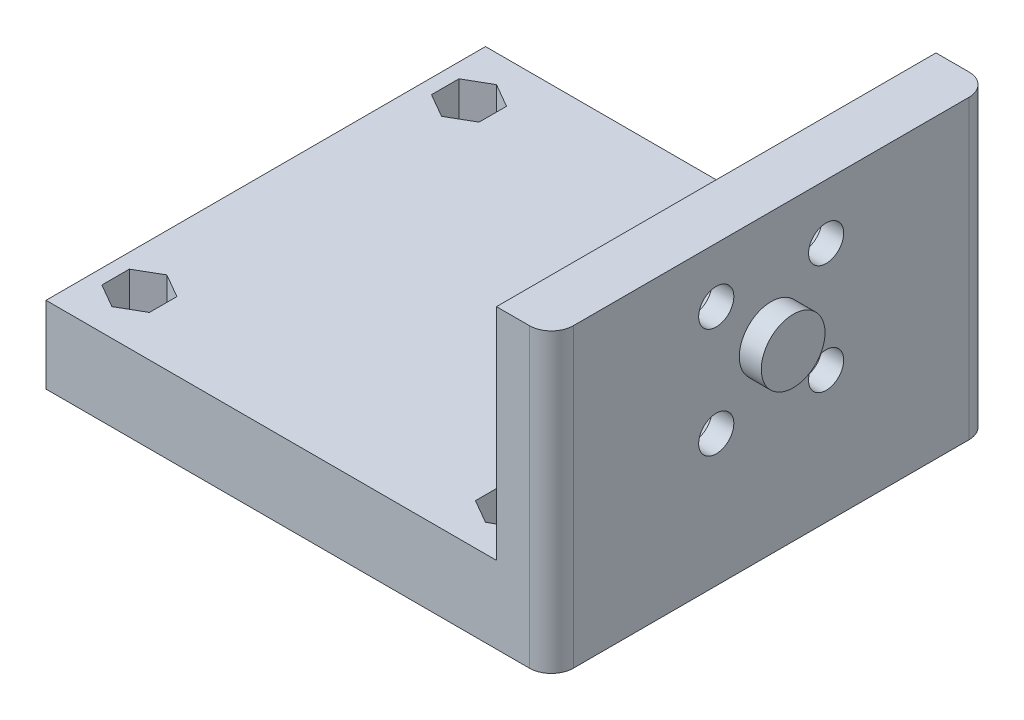
from build123d import *

# Parameters (mm, degrees)
ESQUISSE1_W             = 5
ESQUISSE1_H             = 40
BOSS_EXTRU_1_DEPTH      = 27
ESQUISSE2_W             = 40
ESQUISSE2_H             = 7
BOSS_EXTRU_2_DEPTH      = 41
CONG_1_R                = 2
ENL_V_MAT_EXTRU_1_REACH = 48
ESQUISSE4_R             = 1.6
ESQUISSE5_R             = 2.9
BOSS_EXTRU_3_DEPTH      = 2
ENL_V_MAT_EXTRU_3_DEPTH = 3
ESQUISSE9_R             = 1.1
ENL_V_MAT_EXTRU_5_DEPTH = 8
ENL_V_MAT_EXTRU_4_DEPTH = 4


with BuildPart() as part:
    # Esquisse1 → Boss.-Extru.1 (new body)
    with BuildSketch(Plane(origin=(0, 0, 0), x_dir=(1, 0, 0), z_dir=(0, 1, 0))):
        with Locations((-2.5, 0)):
            Rectangle(ESQUISSE1_W, ESQUISSE1_H)
    extrude(amount=-BOSS_EXTRU_1_DEPTH)

    # Esquisse2 → Boss.-Extru.2 (add)
    with BuildSketch(Plane.ZY.offset(5)):
        with Locations((0, -23.5)):
            Rectangle(ESQUISSE2_W, ESQUISSE2_H)
    extrude(amount=BOSS_EXTRU_2_DEPTH)

    # Congé1
    cong_1_edges = [part.edges().sort_by_distance(p)[0] for p in [
        (0, -13.5, 20),
        (0, -13.5, -20),
    ]]
    fillet(cong_1_edges, radius=CONG_1_R)

    # Esquisse4 → Enlèv. mat.-Extru.1 (cut, up to next)
    with BuildSketch(Plane(origin=(0, 0, 0), x_dir=(0, 0, -1), z_dir=(1, 0, 0)), mode=Mode.PRIVATE) as enl_v_mat_extru_1_sk1:
        with Locations((-5, -5)):
            Circle(ESQUISSE4_R)
    enl_v_mat_extru_1_tool1 = extrude(enl_v_mat_extru_1_sk1.sketch, amount=-ENL_V_MAT_EXTRU_1_REACH, mode=Mode.PRIVATE) & part.part
    add(enl_v_mat_extru_1_tool1.solids().sort_by_distance((0, -5, 5))[0], mode=Mode.SUBTRACT)
    # Esquisse4 → Enlèv. mat.-Extru.1 (cut, up to next)
    with BuildSketch(Plane(origin=(0, 0, 0), x_dir=(0, 0, -1), z_dir=(1, 0, 0)), mode=Mode.PRIVATE) as enl_v_mat_extru_1_sk2:
        with Locations((5, -5)):
            Circle(ESQUISSE4_R)
    enl_v_mat_extru_1_tool2 = extrude(enl_v_mat_extru_1_sk2.sketch, amount=-ENL_V_MAT_EXTRU_1_REACH, mode=Mode.PRIVATE) & part.part
    add(enl_v_mat_extru_1_tool2.solids().sort_by_distance((0, -5, -5))[0], mode=Mode.SUBTRACT)
    # Esquisse4 → Enlèv. mat.-Extru.1 (cut, up to next)
    with BuildSketch(Plane(origin=(0, 0, 0), x_dir=(0, 0, -1), z_dir=(1, 0, 0)), mode=Mode.PRIVATE) as enl_v_mat_extru_1_sk3:
        with Locations((-5, -15)):
            Circle(ESQUISSE4_R)
    enl_v_mat_extru_1_tool3 = extrude(enl_v_mat_extru_1_sk3.sketch, amount=-ENL_V_MAT_EXTRU_1_REACH, mode=Mode.PRIVATE) & part.part
    add(enl_v_mat_extru_1_tool3.solids().sort_by_distance((0, -15, 5))[0], mode=Mode.SUBTRACT)
    # Esquisse4 → Enlèv. mat.-Extru.1 (cut, up to next)
    with BuildSketch(Plane(origin=(0, 0, 0), x_dir=(0, 0, -1), z_dir=(1, 0, 0)), mode=Mode.PRIVATE) as enl_v_mat_extru_1_sk4:
        with Locations((5, -15)):
            Circle(ESQUISSE4_R)
    enl_v_mat_extru_1_tool4 = extrude(enl_v_mat_extru_1_sk4.sketch, amount=-ENL_V_MAT_EXTRU_1_REACH, mode=Mode.PRIVATE) & part.part
    add(enl_v_mat_extru_1_tool4.solids().sort_by_distance((0, -15, -5))[0], mode=Mode.SUBTRACT)

    # Esquisse5 → Boss.-Extru.3 (add)
    with BuildSketch(Plane(origin=(0, 0, 0), x_dir=(0, 0, -1), z_dir=(1, 0, 0))):
        with Locations((0, -10)):
            Circle(ESQUISSE5_R)
    extrude(amount=BOSS_EXTRU_3_DEPTH)

    # Esquisse7 → Enlèv. mat.-Extru.3 (cut)
    with BuildSketch(Plane.ZY.offset(5)):
        Polygon((-3.25, -8.031088913), (-1.5, -5), (-3.25, -1.968911087), (-6.75, -1.968911087), (-8.5, -5), (-6.75, -8.031088913), align=None)
        Polygon((3.25, -1.968911087), (1.5, -5), (3.25, -8.031088913), (6.75, -8.031088913), (8.5, -5), (6.75, -1.968911087), align=None)
        Polygon((-3.25, -18.031088913), (-1.5, -15), (-3.25, -11.968911087), (-6.75, -11.968911087), (-8.5, -15), (-6.75, -18.031088913), align=None)
        Polygon((8.5, -15), (6.75, -11.968911087), (3.25, -11.968911087), (1.5, -15), (3.25, -18.031088913), (6.75, -18.031088913), align=None)
    extrude(amount=-ENL_V_MAT_EXTRU_3_DEPTH, mode=Mode.SUBTRACT)

    # Esquisse9 → Enlèv. mat.-Extru.5 (cut, through all)
    with BuildSketch(Plane(origin=(0, -20, 0), x_dir=(1, 0, 0), z_dir=(0, 1, 0))):
        with Locations(Location((-8.5, 15, 0), (0, 0, 270))):  # turned: the seam where the file's is
            Circle(ESQUISSE9_R)
        with Locations(Location((-8.5, -15, 0), (0, 0, 270))):  # turned: the seam where the file's is
            Circle(ESQUISSE9_R)
        with Locations(Location((-42.5, -15, 0), (0, 0, 270))):  # turned: the seam where the file's is
            Circle(ESQUISSE9_R)
        with Locations(Location((-42.5, 15, 0), (0, 0, 270))):  # turned: the seam where the file's is
            Circle(ESQUISSE9_R)
    extrude(amount=-ENL_V_MAT_EXTRU_5_DEPTH, mode=Mode.SUBTRACT)

    # Esquisse8 → Enlèv. mat.-Extru.4 (cut)
    with BuildSketch(Plane(origin=(0, -20, 0), x_dir=(1, 0, 0), z_dir=(0, 1, 0))):
        Polygon((-10.665063509, 13.75), (-8.5, 12.5), (-6.334936491, 13.75), (-6.334936491, 16.25), (-8.5, 17.5), (-10.665063509, 16.25), align=None)
        Polygon((-10.665063509, -16.25), (-8.5, -17.5), (-6.334936491, -16.25), (-6.334936491, -13.75), (-8.5, -12.5), (-10.665063509, -13.75), align=None)
        Polygon((-44.665063509, -16.25), (-42.5, -17.5), (-40.334936491, -16.25), (-40.334936491, -13.75), (-42.5, -12.5), (-44.665063509, -13.75), align=None)
        Polygon((-42.5, 12.5), (-40.334936491, 13.75), (-40.334936491, 16.25), (-42.5, 17.5), (-44.665063509, 16.25), (-44.665063509, 13.75), align=None)
    extrude(amount=-ENL_V_MAT_EXTRU_4_DEPTH, mode=Mode.SUBTRACT)


solid = part.part
